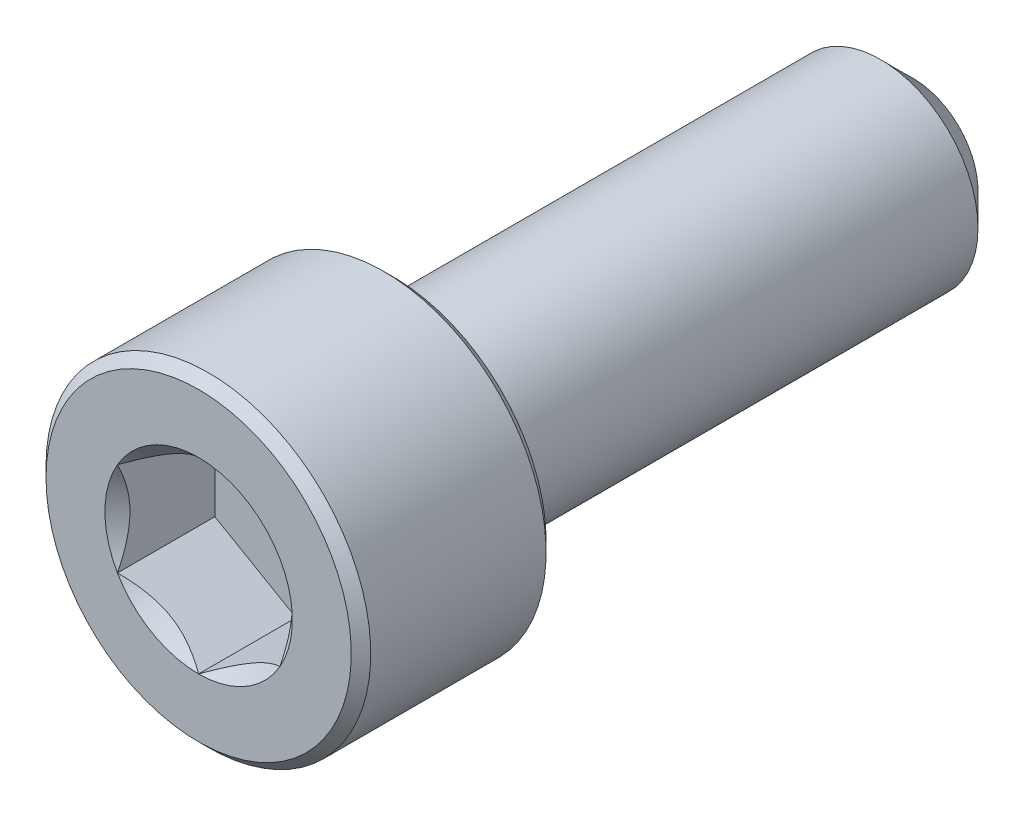
from build123d import *

# Parameters (mm, degrees)
CUT_EXTRUDE1_START = -3
CUT_EXTRUDE1_DEPTH = 3
SKETCH4_R          = 2.886751346
CUT_EXTRUDE2_DEPTH = 0.5
CUT_EXTRUDE2_TAPER = 45


with BuildPart() as part:
    # Sketch2 → Revolve1 (revolve)
    with BuildSketch(Plane(origin=(0, 0, 0), x_dir=(0, 0, -1), z_dir=(1, 0, 0))):
        Polygon((-10.7, 5), (-5.3, 5), (-5, 4.7), (-5, 3), (10, 3), (11, 2), (11, 0), (-11, 0), (-11, 4.7), align=None)
    revolve(axis=Axis((0, 0, -11), (0, 0, 1)))

    # Sketch3 → Cut-Extrude1 (cut)
    with BuildSketch(Plane.XY.offset(11).offset(CUT_EXTRUDE1_START)):
        Polygon((0, 2.886751346), (-2.5, 1.443375673), (-2.5, -1.443375673), (0, -2.886751346), (2.5, -1.443375673), (2.5, 1.443375673), align=None)
    extrude(amount=CUT_EXTRUDE1_DEPTH, mode=Mode.SUBTRACT)

    # Sketch4 → Cut-Extrude2 (cut)
    with BuildSketch(Plane.XY.offset(11)):
        Circle(SKETCH4_R)
    extrude(amount=-CUT_EXTRUDE2_DEPTH, taper=CUT_EXTRUDE2_TAPER, mode=Mode.SUBTRACT)


solid = part.part
